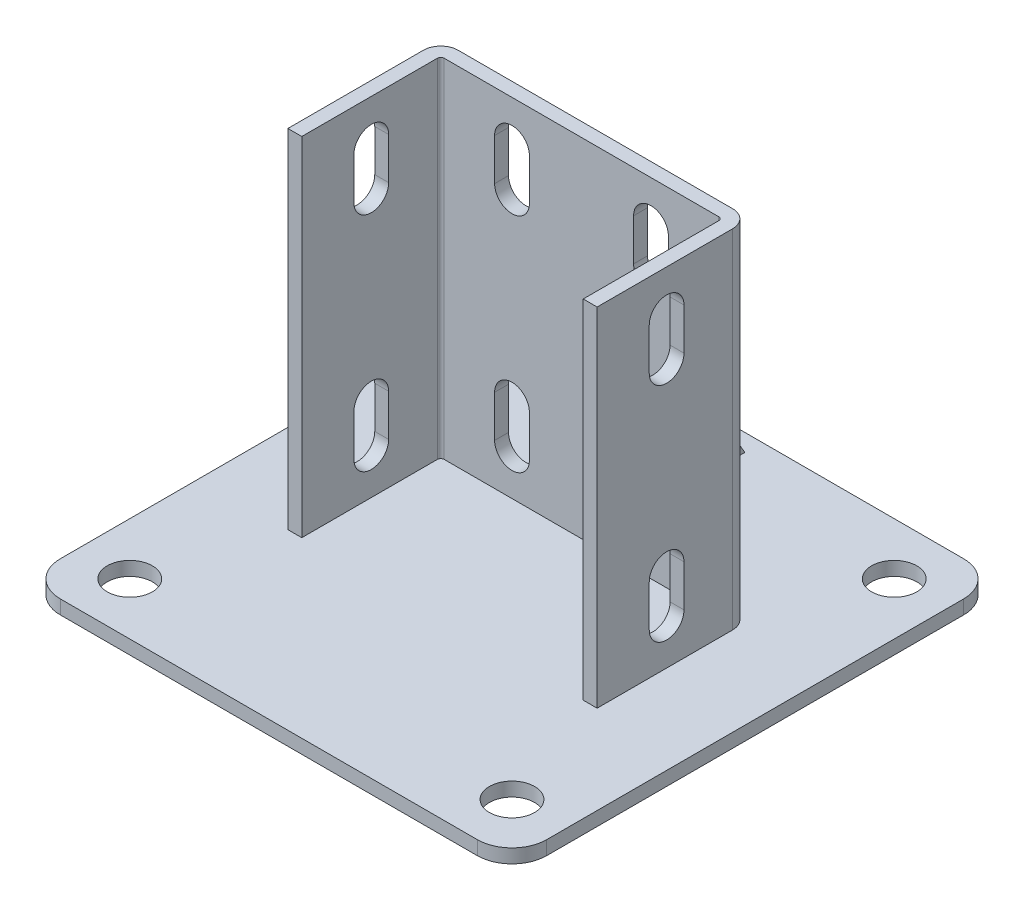
from build123d import *

# Parameters (mm, degrees)
SKETCH_2_W          = 140
SKETCH_2_H          = 140
EXTRUDE_1_DEPTH     = 4
EXTRUDE_1_2_DEPTH   = 100
EXTRUDE_2_DEPTH     = 2
CUT_EXTRUDE_1_DEPTH = 115.5
SKETCH_6_R          = 6.5
CUT_EXTRUDE_2_DEPTH = 5
FILLET_1_R          = 10
CUT_EXTRUDE_3_REACH = 96


with BuildPart() as part:
    # Эскиз2 → Extrude 1 (new body)
    with BuildSketch(Plane(origin=(0, 0, 0), x_dir=(1, 0, 0), z_dir=(0, 1, 0))):
        Rectangle(SKETCH_2_W, SKETCH_2_H)
    extrude(amount=EXTRUDE_1_DEPTH)

    # Эскиз3 → Extrude 1 2 (add)
    with BuildSketch(Plane(origin=(0, 4, 0), x_dir=(1, 0, 0), z_dir=(0, 1, 0))):
        with BuildLine():
            Line((-40.5, -20), (-40.5, 19))
            ThreePointArc((-40.5, 19), (-40.207106781, 19.707106781), (-39.5, 20))
            Line((-39.5, 20), (39.5, 20))
            ThreePointArc((39.5, 20), (40.207106781, 19.707106781), (40.5, 19))
            Line((40.5, 19), (40.5, -20))
            Line((40.5, -20), (44.5, -20))
            Line((44.5, -20), (44.5, 19))
            ThreePointArc((44.5, 19), (43.035533906, 22.535533906), (39.5, 24))
            Line((39.5, 24), (-39.5, 24))
            ThreePointArc((-39.5, 24), (-43.035533906, 22.535533906), (-44.5, 19))
            Line((-44.5, 19), (-44.5, -20))
            Line((-44.5, -20), (-40.5, -20))
        make_face()
    extrude(amount=EXTRUDE_1_2_DEPTH)

    # Эскиз4 → Бобышка-Вытянуть2 (add, symmetric)
    with BuildSketch(Plane(origin=(0, 0, 0), x_dir=(0, 0, -1), z_dir=(1, 0, 0))):
        Polygon((24, 75.01408311), (65, 4), (24, 4), align=None)
    extrude(amount=EXTRUDE_2_DEPTH, both=True)

    # Эскиз5 → Вырез-Вытянуть1 (cut, through all)
    with BuildSketch(Plane(origin=(44.5, 0, 0), x_dir=(0, 0, -1), z_dir=(1, 0, 0))):
        with BuildLine():
            Line((5, 92), (5, 80))
            ThreePointArc((5, 80), (0, 75), (-5, 80))
            Line((-5, 80), (-5, 92))
            ThreePointArc((-5, 92), (0, 97), (5, 92))
        make_face()
        with BuildLine():
            Line((5, 28), (5, 16))
            ThreePointArc((5, 16), (0, 11), (-5, 16))
            Line((-5, 16), (-5, 28))
            ThreePointArc((-5, 28), (0, 33), (5, 28))
        make_face()
    extrude(amount=-CUT_EXTRUDE_1_DEPTH, mode=Mode.SUBTRACT)

    # Эскиз6 → Вырез-Вытянуть2 (cut, through all)
    with BuildSketch(Plane(origin=(0, 4, 0), x_dir=(1, 0, 0), z_dir=(0, 1, 0))):
        with Locations(Location((-55, 55, 0), (0, 0, 270))):  # turned: the seam where the file's is
            Circle(SKETCH_6_R)
        with Locations(Location((-55, -55, 0), (0, 0, 270))):  # turned: the seam where the file's is
            Circle(SKETCH_6_R)
        with Locations(Location((55, 55, 0), (0, 0, 270))):  # turned: the seam where the file's is
            Circle(SKETCH_6_R)
        with Locations(Location((55, -55, 0), (0, 0, 270))):  # turned: the seam where the file's is
            Circle(SKETCH_6_R)
    extrude(amount=-CUT_EXTRUDE_2_DEPTH, mode=Mode.SUBTRACT)

    # Скругление1
    fillet_1_edges = [part.edges().sort_by_distance(p)[0] for p in [
        (70, 2, 70),
        (-70, 2, 70),
        (-70, 2, -70),
        (70, 2, -70),
    ]]
    fillet(fillet_1_edges, radius=FILLET_1_R)

    # Эскиз8 → Вырез-Вытянуть3 (cut, up to next)
    with BuildSketch(Plane(origin=(0, 0, -24), x_dir=(-1, 0, 0), z_dir=(0, 0, -1)), mode=Mode.PRIVATE) as cut_extrude_3_sk1:
        with BuildLine():
            Line((-15, 92), (-15, 80))
            ThreePointArc((-15, 80), (-20, 75), (-25, 80))
            Line((-25, 80), (-25, 92))
            ThreePointArc((-25, 92), (-20, 97), (-15, 92))
        make_face()
    cut_extrude_3_tool1 = extrude(cut_extrude_3_sk1.sketch, amount=-CUT_EXTRUDE_3_REACH, mode=Mode.PRIVATE) & part.part
    add(cut_extrude_3_tool1.solids().sort_by_distance((20, 86, -24))[0], mode=Mode.SUBTRACT)
    # Эскиз8 → Вырез-Вытянуть3 (cut, up to next)
    with BuildSketch(Plane(origin=(0, 0, -24), x_dir=(-1, 0, 0), z_dir=(0, 0, -1)), mode=Mode.PRIVATE) as cut_extrude_3_sk2:
        with BuildLine():
            Line((-15, 28), (-15, 16))
            ThreePointArc((-15, 16), (-20, 11), (-25, 16))
            Line((-25, 16), (-25, 28))
            ThreePointArc((-25, 28), (-20, 33), (-15, 28))
        make_face()
    cut_extrude_3_tool2 = extrude(cut_extrude_3_sk2.sketch, amount=-CUT_EXTRUDE_3_REACH, mode=Mode.PRIVATE) & part.part
    add(cut_extrude_3_tool2.solids().sort_by_distance((20, 22, -24))[0], mode=Mode.SUBTRACT)
    # Эскиз8 → Вырез-Вытянуть3 (cut, up to next)
    with BuildSketch(Plane(origin=(0, 0, -24), x_dir=(-1, 0, 0), z_dir=(0, 0, -1)), mode=Mode.PRIVATE) as cut_extrude_3_sk3:
        with BuildLine():
            Line((15, 92), (15, 80))
            ThreePointArc((15, 80), (20, 75), (25, 80))
            Line((25, 80), (25, 92))
            ThreePointArc((25, 92), (20, 97), (15, 92))
        make_face()
    cut_extrude_3_tool3 = extrude(cut_extrude_3_sk3.sketch, amount=-CUT_EXTRUDE_3_REACH, mode=Mode.PRIVATE) & part.part
    add(cut_extrude_3_tool3.solids().sort_by_distance((-20, 86, -24))[0], mode=Mode.SUBTRACT)
    # Эскиз8 → Вырез-Вытянуть3 (cut, up to next)
    with BuildSketch(Plane(origin=(0, 0, -24), x_dir=(-1, 0, 0), z_dir=(0, 0, -1)), mode=Mode.PRIVATE) as cut_extrude_3_sk4:
        with BuildLine():
            Line((15, 28), (15, 16))
            ThreePointArc((15, 16), (20, 11), (25, 16))
            Line((25, 16), (25, 28))
            ThreePointArc((25, 28), (20, 33), (15, 28))
        make_face()
    cut_extrude_3_tool4 = extrude(cut_extrude_3_sk4.sketch, amount=-CUT_EXTRUDE_3_REACH, mode=Mode.PRIVATE) & part.part
    add(cut_extrude_3_tool4.solids().sort_by_distance((-20, 22, -24))[0], mode=Mode.SUBTRACT)


solid = part.part
